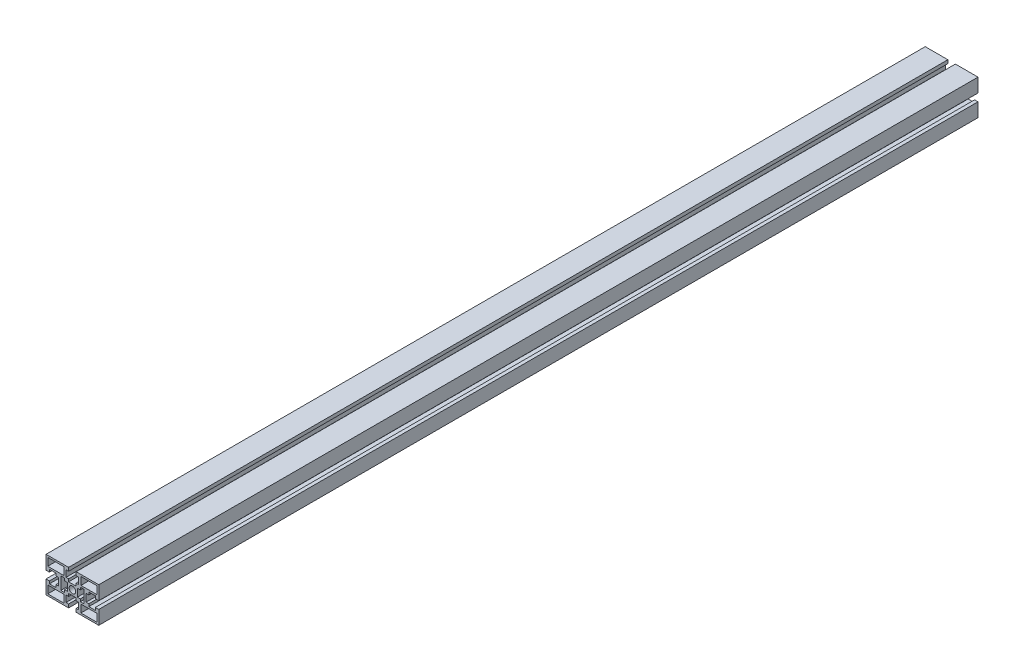
from build123d import *

# Parameters (mm, degrees)
SKETCH_1_R      = 3.75
SKETCH_1_W      = 18.3
SKETCH_1_H      = 8.8
EXTRUDE_1_DEPTH = 1000


with BuildPart() as part:
    # Эскиз1 → Бобышка-Вытянуть1 (new body)
    with BuildSketch(Plane.XY):
        Polygon((-30, 7.2), (-30, 20), (-7.2, 20), (-4.3, 20), (-4.3, 16.1), (-7.2, 16.1), (-7.2, 8.7), (-4.3, 8.7), (-4.3, 5.7), (4.3, 5.7), (4.3, 8.7), (7.2, 8.7), (7.2, 16.1), (4.3, 16.1), (4.3, 20), (7.2, 20), (30, 20), (30, 7.2), (30, 4.3), (26.1, 4.3), (26.1, 7.2), (18.7, 7.2), (18.7, 4.3), (15.7, 4.3), (15.7, -4.3), (18.7, -4.3), (18.7, -7.2), (26.1, -7.2), (26.1, -4.3), (30, -4.3), (30, -7.2), (30, -20), (7.2, -20), (4.3, -20), (4.3, -16.1), (7.2, -16.1), (7.2, -8.7), (4.3, -8.7), (4.3, -5.7), (-4.3, -5.7), (-4.3, -8.7), (-7.2, -8.7), (-7.2, -16.1), (-4.3, -16.1), (-4.3, -20), (-7.2, -20), (-30, -20), (-30, -7.2), (-30, -4.3), (-26.1, -4.3), (-26.1, -7.2), (-18.7, -7.2), (-18.7, -4.3), (-15.7, -4.3), (-15.7, 4.3), (-18.7, 4.3), (-18.7, 7.2), (-26.1, 7.2), (-26.1, 4.3), (-30, 4.3), align=None)
        Circle(SKETCH_1_R, mode=Mode.SUBTRACT)
        Polygon((-13.2, -7.2), (-13.2, 7.2), (-9, 7.2), (-9, 4.4), (-5.7, 4.4), (-5.7, -4.4), (-9, -4.4), (-9, -7.2), align=None, mode=Mode.SUBTRACT)
        with Locations((-18.85, 13.6)):
            Rectangle(SKETCH_1_W, SKETCH_1_H, mode=Mode.SUBTRACT)
        with Locations((-18.85, -13.6)):
            Rectangle(SKETCH_1_W, SKETCH_1_H, mode=Mode.SUBTRACT)
        with Locations((18.85, -13.6)):
            Rectangle(SKETCH_1_W, SKETCH_1_H, mode=Mode.SUBTRACT)
        Polygon((9, 4.4), (5.7, 4.4), (5.7, -4.4), (9, -4.4), (9, -7.2), (13.2, -7.2), (13.2, 7.2), (9, 7.2), align=None, mode=Mode.SUBTRACT)
        with Locations((18.85, 13.6)):
            Rectangle(SKETCH_1_W, SKETCH_1_H, mode=Mode.SUBTRACT)
    extrude(amount=EXTRUDE_1_DEPTH)


solid = part.part
